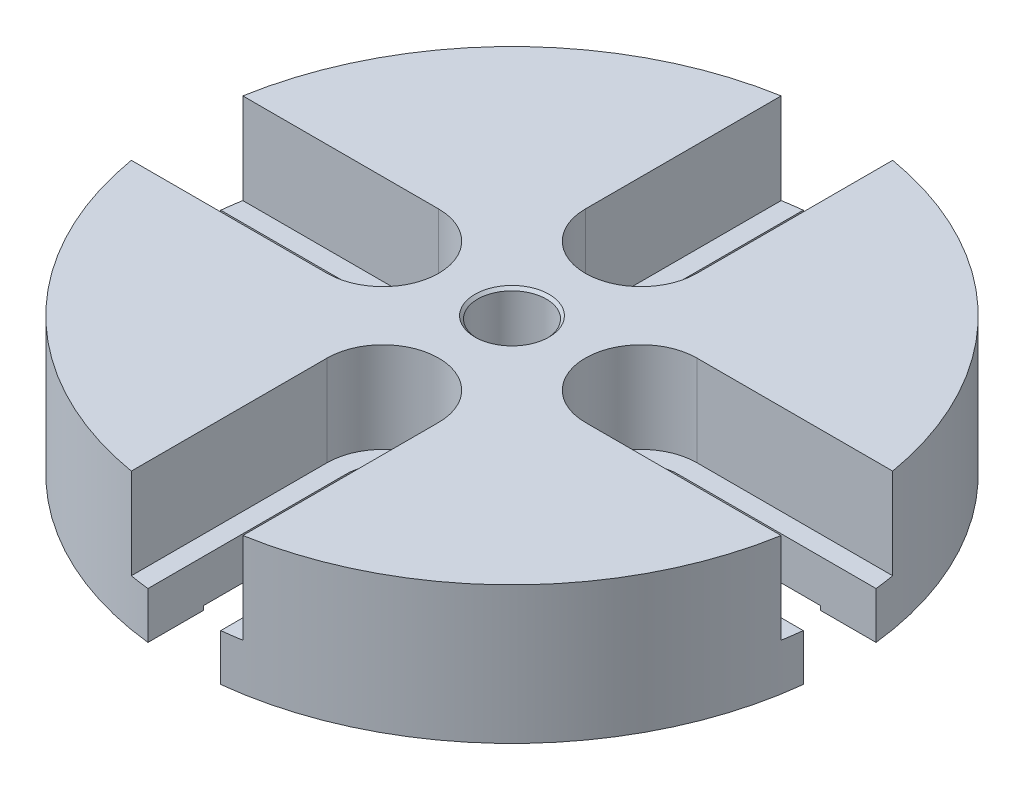
from build123d import *

# Parameters (mm, degrees)
SKETCH1_W          = 30.48
SKETCH1_H          = 12.7
CUT_EXTRUDE1_DEPTH = 8.382
CUT_EXTRUDE2_DEPTH = 5.318
CUT_EXTRUDE3_DEPTH = 8.382
CUT_EXTRUDE4_DEPTH = 5.318
CUT_EXTRUDE5_DEPTH = 8.382
CUT_EXTRUDE6_DEPTH = 5.318
CUT_EXTRUDE7_DEPTH = 8.382
CUT_EXTRUDE8_DEPTH = 5.318
HOLE1_D            = 6.35
HOLE1_DEPTH        = 12.7
HOLE1_CBORE_D      = 50.8
HOLE1_CBORE_DEPTH  = 0.381
CHAMFER1_SIZE      = 0.254


with BuildPart() as part:
    # Sketch1 → Revolve1 (revolve)
    with BuildSketch(Plane(origin=(0, 0, 0), x_dir=(-1, 0, 0), z_dir=(0, 0, -1))):
        with Locations((-15.24, 0)):
            Rectangle(SKETCH1_W, SKETCH1_H)
    revolve(axis=Axis((0, -6.35, 0), (0, 1, 0)))

    # Sketch2 → Cut-Extrude1 (cut)
    with BuildSketch(Plane(origin=(0, 6.35, 0), x_dir=(-1, 0, 0), z_dir=(0, 1, 0))):
        with BuildLine():
            Line((5.1562, -30.040705743), (5.1562, -11.938))
            ThreePointArc((5.1562, -11.938), (0, -6.7818), (-5.1562, -11.938))
            Line((-5.1562, -11.938), (-5.1562, -30.040705743))
            ThreePointArc((-5.1562, -30.040705743), (0, -30.48), (5.1562, -30.040705743))
        make_face()
    extrude(amount=-CUT_EXTRUDE1_DEPTH, mode=Mode.SUBTRACT)

    # Sketch3 → Cut-Extrude2 (cut, through all)
    with BuildSketch(Plane(origin=(0, -2.032, 0), x_dir=(-1, 0, 0), z_dir=(0, 1, 0))):
        with BuildLine():
            Line((3.3655, -30.293626553), (3.3655, -11.938))
            ThreePointArc((3.3655, -11.938), (0, -8.5725), (-3.3655, -11.938))
            Line((-3.3655, -11.938), (-3.3655, -30.293626553))
            ThreePointArc((-3.3655, -30.293626553), (0, -30.48), (3.3655, -30.293626553))
        make_face()
    extrude(amount=-CUT_EXTRUDE2_DEPTH, mode=Mode.SUBTRACT)

    # Sketch4 → Cut-Extrude3 (cut)
    with BuildSketch(Plane(origin=(0, 6.35, 0), x_dir=(-1, 0, 0), z_dir=(0, 1, 0))):
        with BuildLine():
            Line((-30.040705743, -5.1562), (-11.938, -5.1562))
            ThreePointArc((-11.938, -5.1562), (-6.7818, 0), (-11.938, 5.1562))
            Line((-11.938, 5.1562), (-30.040705743, 5.1562))
            ThreePointArc((-30.040705743, 5.1562), (-30.48, 0), (-30.040705743, -5.1562))
        make_face()
    extrude(amount=-CUT_EXTRUDE3_DEPTH, mode=Mode.SUBTRACT)

    # Sketch5 → Cut-Extrude4 (cut, through all)
    with BuildSketch(Plane(origin=(0, -2.032, 0), x_dir=(-1, 0, 0), z_dir=(0, 1, 0))):
        with BuildLine():
            Line((-30.293626553, -3.3655), (-11.938, -3.3655))
            ThreePointArc((-11.938, -3.3655), (-8.5725, 0), (-11.938, 3.3655))
            Line((-11.938, 3.3655), (-30.293626553, 3.3655))
            ThreePointArc((-30.293626553, 3.3655), (-30.48, 0), (-30.293626553, -3.3655))
        make_face()
    extrude(amount=-CUT_EXTRUDE4_DEPTH, mode=Mode.SUBTRACT)

    # Sketch6 → Cut-Extrude5 (cut)
    with BuildSketch(Plane(origin=(0, 6.35, 0), x_dir=(-1, 0, 0), z_dir=(0, 1, 0))):
        with BuildLine():
            Line((-5.1562, 30.040705743), (-5.1562, 11.938))
            ThreePointArc((-5.1562, 11.938), (0, 6.7818), (5.1562, 11.938))
            Line((5.1562, 11.938), (5.1562, 30.040705743))
            ThreePointArc((5.1562, 30.040705743), (0, 30.48), (-5.1562, 30.040705743))
        make_face()
    extrude(amount=-CUT_EXTRUDE5_DEPTH, mode=Mode.SUBTRACT)

    # Sketch7 → Cut-Extrude6 (cut, through all)
    with BuildSketch(Plane(origin=(0, -2.032, 0), x_dir=(-1, 0, 0), z_dir=(0, 1, 0))):
        with BuildLine():
            Line((-3.3655, 30.293626553), (-3.3655, 11.938))
            ThreePointArc((-3.3655, 11.938), (0, 8.5725), (3.3655, 11.938))
            Line((3.3655, 11.938), (3.3655, 30.293626553))
            ThreePointArc((3.3655, 30.293626553), (0, 30.48), (-3.3655, 30.293626553))
        make_face()
    extrude(amount=-CUT_EXTRUDE6_DEPTH, mode=Mode.SUBTRACT)

    # Sketch8 → Cut-Extrude7 (cut)
    with BuildSketch(Plane(origin=(0, 6.35, 0), x_dir=(-1, 0, 0), z_dir=(0, 1, 0))):
        with BuildLine():
            Line((30.040705743, 5.1562), (11.938, 5.1562))
            ThreePointArc((11.938, 5.1562), (6.7818, 0), (11.938, -5.1562))
            Line((11.938, -5.1562), (30.040705743, -5.1562))
            ThreePointArc((30.040705743, -5.1562), (30.48, 0), (30.040705743, 5.1562))
        make_face()
    extrude(amount=-CUT_EXTRUDE7_DEPTH, mode=Mode.SUBTRACT)

    # Sketch9 → Cut-Extrude8 (cut, through all)
    with BuildSketch(Plane(origin=(0, -2.032, 0), x_dir=(-1, 0, 0), z_dir=(0, 1, 0))):
        with BuildLine():
            Line((30.293626553, 3.3655), (11.938, 3.3655))
            ThreePointArc((11.938, 3.3655), (8.5725, 0), (11.938, -3.3655))
            Line((11.938, -3.3655), (30.293626553, -3.3655))
            ThreePointArc((30.293626553, -3.3655), (30.48, 0), (30.293626553, 3.3655))
        make_face()
    extrude(amount=-CUT_EXTRUDE8_DEPTH, mode=Mode.SUBTRACT)

    # Hole1
    with Locations(Plane(origin=(0, -6.35, 0), x_dir=(-1, 0, 0), z_dir=(0, -1, 0))):
        with Locations((0, 0)):
            CounterBoreHole(HOLE1_D / 2, HOLE1_CBORE_D / 2, HOLE1_CBORE_DEPTH, depth=HOLE1_DEPTH)

    # Chamfer1
    chamfer1_edges = [part.edges().sort_by_distance(p)[0] for p in [
        (-3.175, -5.969, 0),
        (-3.175, 6.35, 0),
    ]]
    chamfer(chamfer1_edges, length=CHAMFER1_SIZE)


solid = part.part
